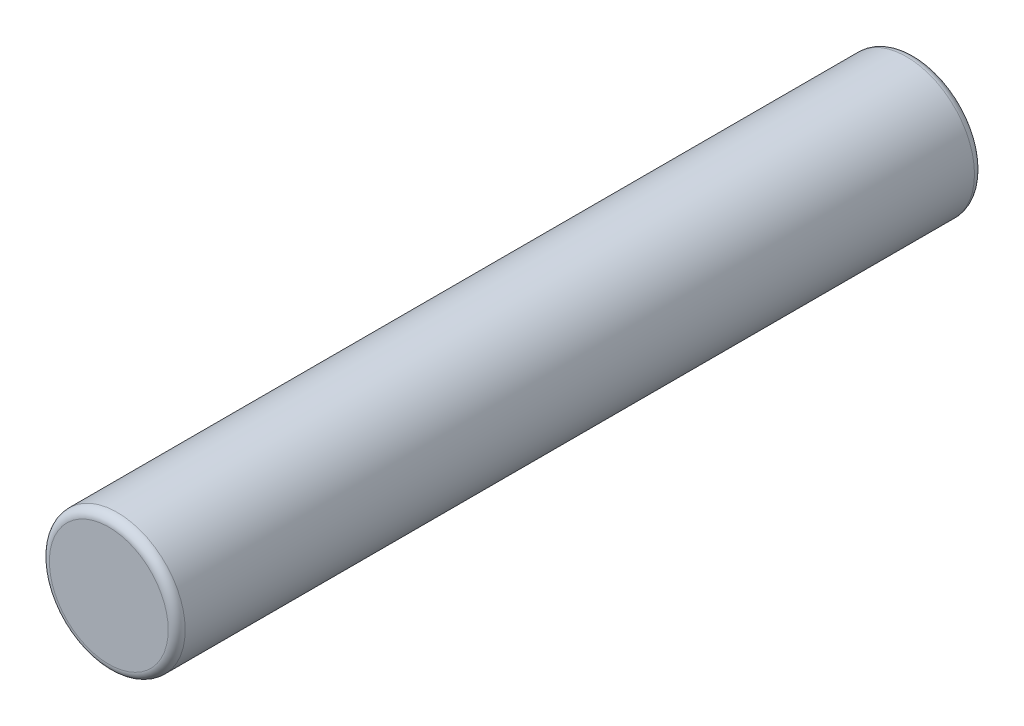
from build123d import *

# Parameters (mm, degrees)
SKETCH1_R           = 0.8
BOSS_EXTRUDE1_DEPTH = 9.5
FILLET1_R           = 0.1


with BuildPart() as part:
    # Sketch1 → Boss-Extrude1 (new body)
    with BuildSketch(Plane.XY):
        Circle(SKETCH1_R)
    extrude(amount=BOSS_EXTRUDE1_DEPTH)

    # Fillet1
    fillet1_edges = [part.edges().sort_by_distance(p)[0] for p in [
        (-0.8, 0, 0),
        (-0.8, 0, 9.5),
    ]]
    fillet(fillet1_edges, radius=FILLET1_R)


solid = part.part
